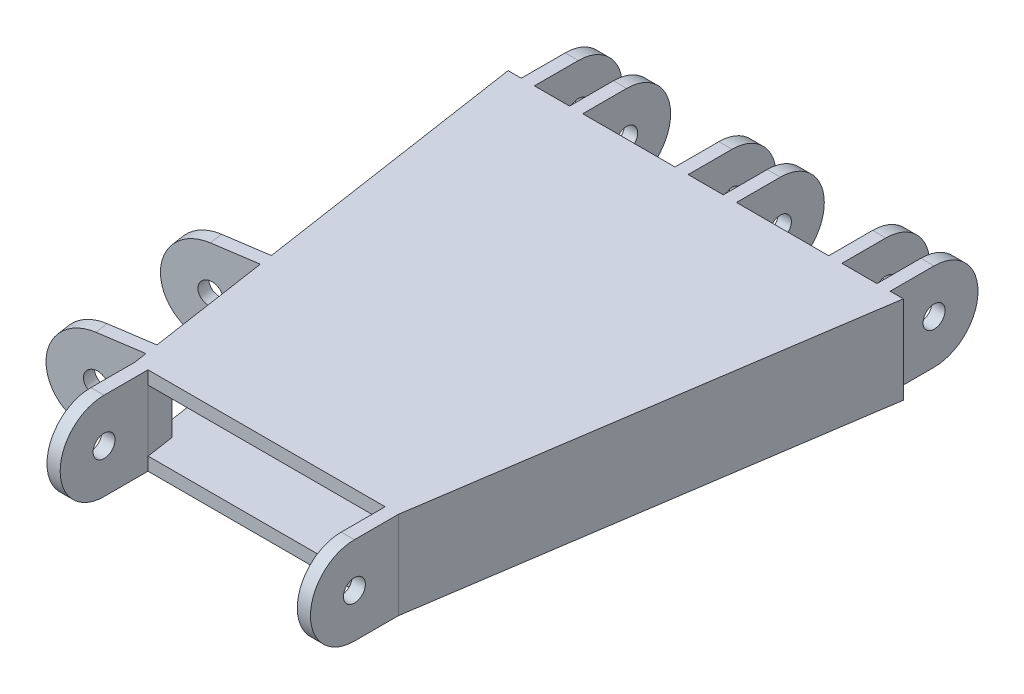
from build123d import *

# Parameters (mm, degrees)
BOSS_EXTRUDE1_DEPTH = 10
BOSS_EXTRUDE2_START = 35
SKETCH2_R           = 2.5
BOSS_EXTRUDE2_DEPTH = 7
LPATTERN1_COUNT     = 3
LPATTERN1_PITCH     = 35
SHELL1_T            = -3
SKETCH3_W           = 8
SKETCH3_H           = 20
CUT_EXTRUDE1_DEPTH  = 20
BOSS_EXTRUDE3_START = 3
SKETCH5_R           = 2.5
BOSS_EXTRUDE3_DEPTH = 3
LPATTERN2_COUNT     = 2
LPATTERN2_PITCH     = 31
SKETCH6_W           = 28
SKETCH6_H           = 14
CUT_EXTRUDE2_DEPTH  = 3
BOSS_EXTRUDE4_START = 30
SKETCH7_R           = 2.5
BOSS_EXTRUDE4_DEPTH = 3
LPATTERN3_COUNT     = 2
LPATTERN3_PITCH     = 57


with BuildPart() as part:
    # Sketch1 → Boss-Extrude1 (new body, symmetric)
    with BuildSketch(Plane(origin=(0, 0, 0), x_dir=(1, 0, 0), z_dir=(0, 1, 0))):
        Polygon((-45, 0), (45, 0), (30, -100), (-30, -100), align=None)
    extrude(amount=BOSS_EXTRUDE1_DEPTH, both=True)

    # Sketch2 → Boss-Extrude2 (add, symmetric)
    with BuildSketch(Plane(origin=(0, 0, 0), x_dir=(0, 0, -1), z_dir=(1, 0, 0)).offset(BOSS_EXTRUDE2_START)):
        with BuildLine():
            Line((0, 10), (10, 10))
            ThreePointArc((10, 10), (20, 0), (10, -10))
            Line((10, -10), (0, -10))
            Line((0, -10), (0, 10))
        make_face()
        with Locations((10, 0)):
            Circle(SKETCH2_R, mode=Mode.SUBTRACT)
    boss_extrude2 = extrude(amount=BOSS_EXTRUDE2_DEPTH, both=True)

    # LPattern1: Boss-Extrude2 ×3
    with Locations(*[(-i * LPATTERN1_PITCH, 0, 0) for i in range(1, LPATTERN1_COUNT)]):
        add(boss_extrude2)

    # Shell1
    shell1_openings = [part.faces().sort_by_distance(p)[0] for p in [
        (0, 0, 100),
    ]]
    offset(amount=SHELL1_T, openings=shell1_openings, kind=Kind.INTERSECTION)

    # Sketch3 → Cut-Extrude1 (cut)
    with BuildSketch(Plane.XY):
        with Locations((35, 0)):
            Rectangle(SKETCH3_W, SKETCH3_H)
        Rectangle(SKETCH3_W, SKETCH3_H)
        with Locations((-35, 0)):
            Rectangle(SKETCH3_W, SKETCH3_H)
    extrude(amount=-CUT_EXTRUDE1_DEPTH, mode=Mode.SUBTRACT)

    # Sketch5 → Boss-Extrude3 (add)
    with BuildSketch(Plane(origin=(14.009779951, 0, 93.398533007), x_dir=(-0.988936353, 0, 0.148340453), z_dir=(-0.148340453, 0, -0.988936353)).offset(BOSS_EXTRUDE3_START)):
        with BuildLine():
            Line((44.502135879, 10), (54.502135879, 10))
            ThreePointArc((54.502135879, 10), (64.502135879, 0), (54.502135879, -10))
            Line((54.502135879, -10), (44.502135879, -10))
            Line((44.502135879, -10), (44.502135879, 10))
        make_face()
        with Locations((54.502135879, 0)):
            Circle(SKETCH5_R, mode=Mode.SUBTRACT)
    boss_extrude3 = extrude(amount=BOSS_EXTRUDE3_DEPTH)

    # LPattern2: Boss-Extrude3 ×2
    with Locations(*[Vector(-0.148340453, 0, -0.988936353) * (i * LPATTERN2_PITCH) for i in range(1, LPATTERN2_COUNT)]):
        add(boss_extrude3)

    # Sketch6 → Cut-Extrude2 (cut)
    with BuildSketch(Plane(origin=(-44.009779951, 0, 6.601466993), x_dir=(-0.148340453, 0, -0.988936353), z_dir=(0.988936353, 0, -0.148340453))):
        with Locations((-74.443421699, 0)):
            Rectangle(SKETCH6_W, SKETCH6_H)
    extrude(amount=CUT_EXTRUDE2_DEPTH, mode=Mode.SUBTRACT)

    # Sketch7 → Boss-Extrude4 (add)
    with BuildSketch(Plane(origin=(0, 0, 0), x_dir=(0, 0, -1), z_dir=(1, 0, 0)).offset(BOSS_EXTRUDE4_START)):
        with BuildLine():
            Line((-100, 10), (-110, 10))
            ThreePointArc((-110, 10), (-120, 0), (-110, -10))
            Line((-110, -10), (-100, -10))
            Line((-100, -10), (-100, 10))
        make_face()
        with Locations((-110, 0)):
            Circle(SKETCH7_R, mode=Mode.SUBTRACT)
    boss_extrude4 = extrude(amount=-BOSS_EXTRUDE4_DEPTH)

    # LPattern3: Boss-Extrude4 ×2
    with Locations(*[(-i * LPATTERN3_PITCH, 0, 0) for i in range(1, LPATTERN3_COUNT)]):
        add(boss_extrude4)


solid = part.part
